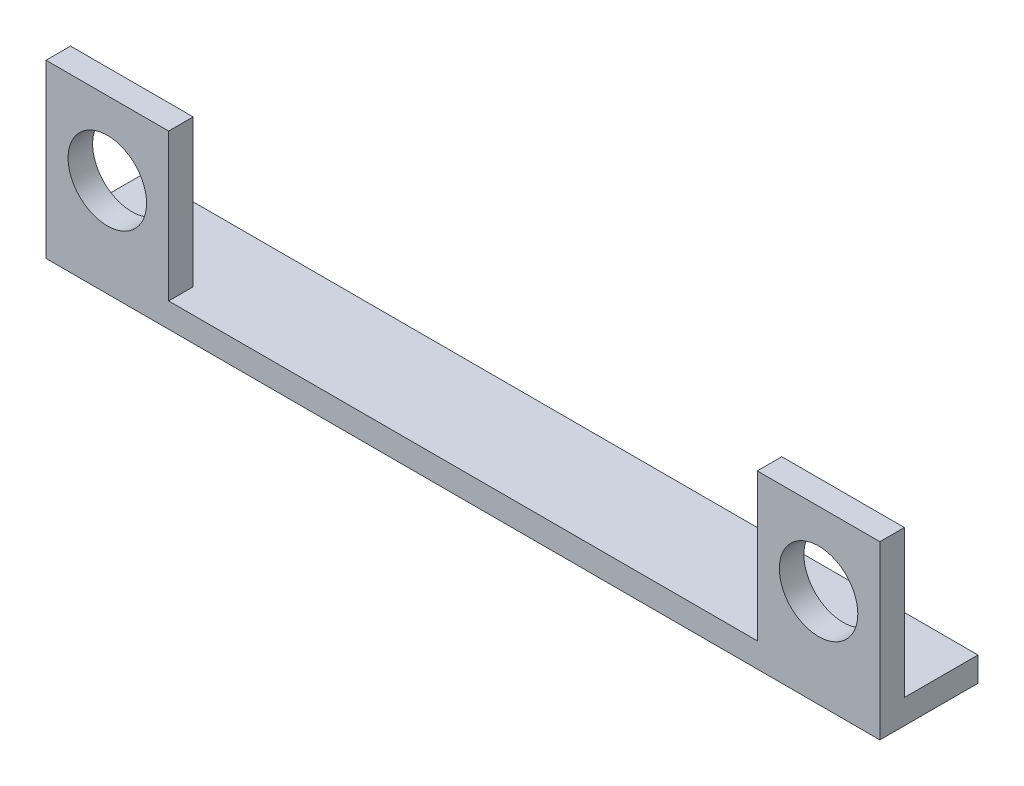
from build123d import *

# Parameters (mm, degrees)
SKETCH1_W           = 34
SKETCH1_H           = 4
BOSS_EXTRUDE1_DEPTH = 1
SKETCH2_W           = 5
SKETCH2_H           = 1
BOSS_EXTRUDE2_DEPTH = 6
SKETCH3_R           = 1.6
CUT_EXTRUDE1_DEPTH  = 6


with BuildPart() as part:
    # Sketch1 → Boss-Extrude1 (new body)
    with BuildSketch(Plane(origin=(0, 0, 0), x_dir=(1, 0, 0), z_dir=(0, 1, 0))):
        Rectangle(SKETCH1_W, SKETCH1_H)
    extrude(amount=BOSS_EXTRUDE1_DEPTH)

    # Sketch2 → Boss-Extrude2 (add)
    with BuildSketch(Plane(origin=(0, 1, 0), x_dir=(1, 0, 0), z_dir=(0, 1, 0))):
        with Locations((-14.5, -1.5)):
            Rectangle(SKETCH2_W, SKETCH2_H)
        with Locations((14.5, -1.5)):
            Rectangle(SKETCH2_W, SKETCH2_H)
    extrude(amount=BOSS_EXTRUDE2_DEPTH)

    # Sketch3 → Cut-Extrude1 (cut)
    with BuildSketch(Plane.XY.offset(2)):
        with Locations((-14.5, 4)):
            Circle(SKETCH3_R)
        with Locations((14.5, 4)):
            Circle(SKETCH3_R)
    extrude(amount=-CUT_EXTRUDE1_DEPTH, mode=Mode.SUBTRACT)


solid = part.part
